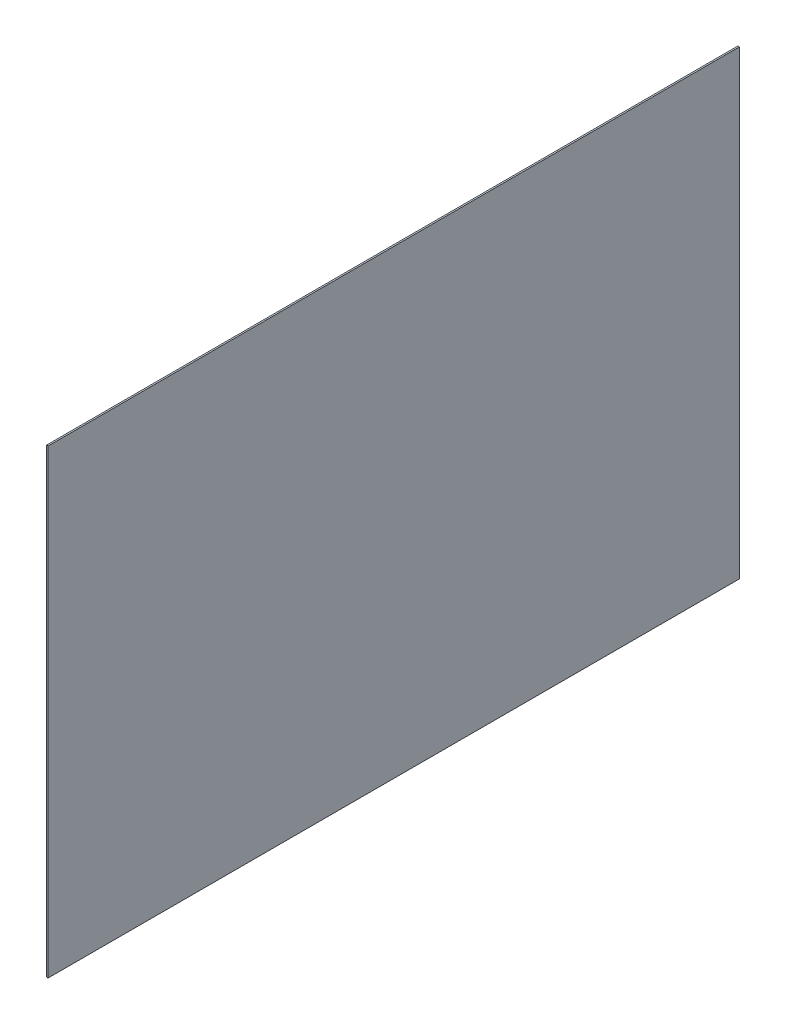
from build123d import *

# Parameters (mm, degrees)
SKETCH1_W           = 450
SKETCH1_H           = 300
BOSS_EXTRUDE1_DEPTH = 1


with BuildPart() as part:
    # Sketch1 → Boss-Extrude1 (new body)
    with BuildSketch(Plane(origin=(0, 0, 0), x_dir=(0, 0, -1), z_dir=(1, 0, 0))):
        Rectangle(SKETCH1_W, SKETCH1_H)
    extrude(amount=BOSS_EXTRUDE1_DEPTH)


solid = part.part
